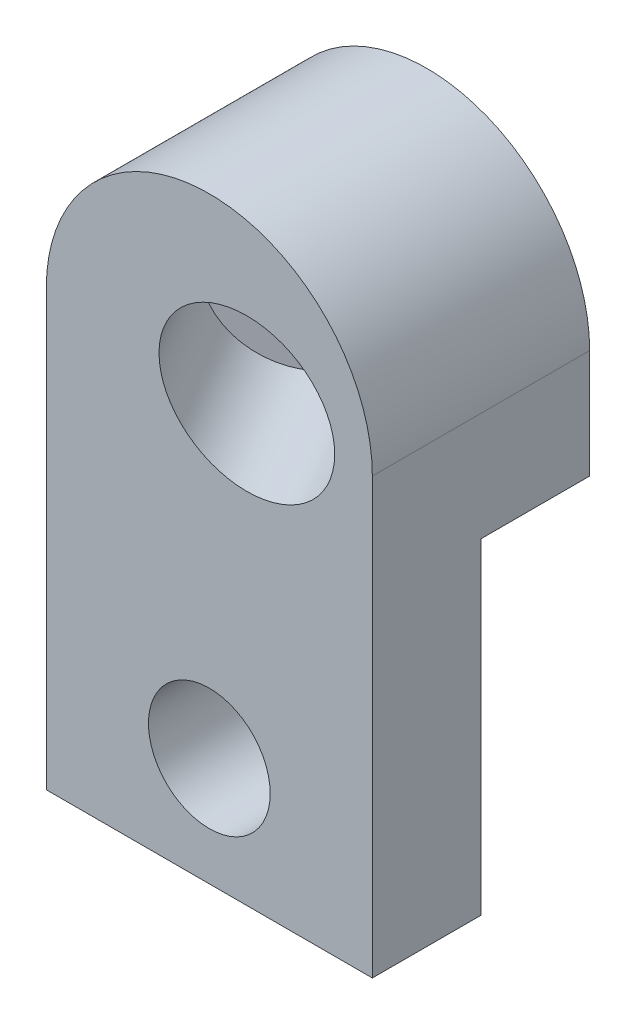
from build123d import *

# Parameters (mm, degrees)
SKETCH2_R           = 2.8
BOSS_EXTRUDE1_DEPTH = 5
BOSS_EXTRUDE2_DEPTH = 5
SKETCH4_R           = 3.5
CUT_EXTRUDE1_DEPTH  = 10


with BuildPart() as part:
    # Sketch2 → Boss-Extrude1 (new body)
    with BuildSketch(Plane.XY):
        with BuildLine():
            Line((0, 0), (15, 0))
            Line((15, 0), (15, 20))
            ThreePointArc((15, 20), (7.5, 27.5), (0, 20))
            Line((0, 20), (0, 0))
        make_face()
        with Locations((7.5, 5)):
            Circle(SKETCH2_R, mode=Mode.SUBTRACT)
    extrude(amount=BOSS_EXTRUDE1_DEPTH)

    # Sketch3 → Boss-Extrude2 (add)
    with BuildSketch(Plane(origin=(0, 0, 0), x_dir=(-1, 0, 0), z_dir=(0, 0, -1))):
        with BuildLine():
            Line((-15, 20), (-15, 15))
            Line((-15, 15), (0, 15))
            Line((0, 15), (0, 20))
            ThreePointArc((0, 20), (-7.5, 27.5), (-15, 20))
        make_face()
    extrude(amount=BOSS_EXTRUDE2_DEPTH)

    # Sketch4 → Cut-Extrude1 (cut)
    with BuildSketch(Plane(origin=(5.915063509, 0, 10.245190528), x_dir=(0, 1, 0), z_dir=(0.5, 0, 0.866025404))):
        with Locations((20, -5.490381057)):
            Circle(SKETCH4_R)
    extrude(amount=-CUT_EXTRUDE1_DEPTH, mode=Mode.SUBTRACT)


solid = part.part
